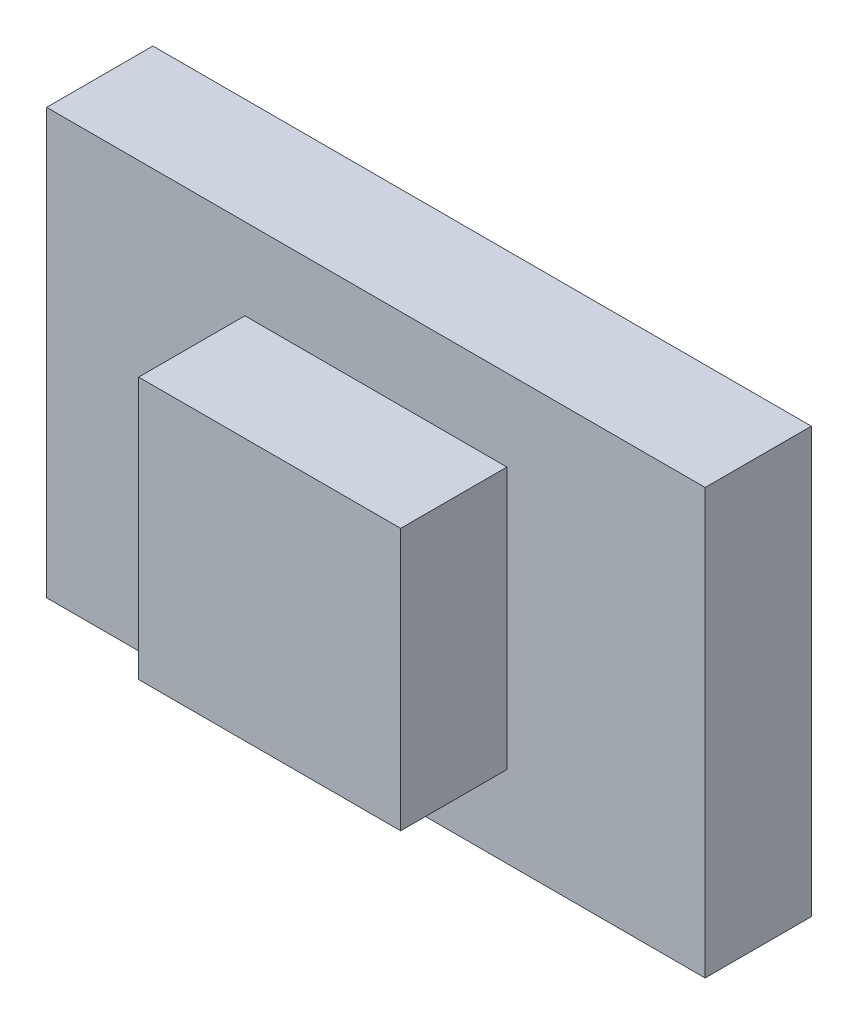
from build123d import *

# Parameters (mm, degrees)
SKETCH1_W           = 60
SKETCH1_H           = 93
BOSS_EXTRUDE1_DEPTH = 15
SKETCH2_W           = 37
SKETCH2_H           = 37
BOSS_EXTRUDE2_DEPTH = 15


with BuildPart() as part:
    # Sketch1 → Boss-Extrude1 (new body)
    with BuildSketch(Plane(origin=(0, 0, 0), x_dir=(0, 1, 0), z_dir=(0, 0, 1))):
        Rectangle(SKETCH1_W, SKETCH1_H)
    extrude(amount=BOSS_EXTRUDE1_DEPTH)

    # Sketch2 → Boss-Extrude2 (add)
    with BuildSketch(Plane.XY.offset(15)):
        Rectangle(SKETCH2_W, SKETCH2_H)
    extrude(amount=BOSS_EXTRUDE2_DEPTH)


solid = part.part
